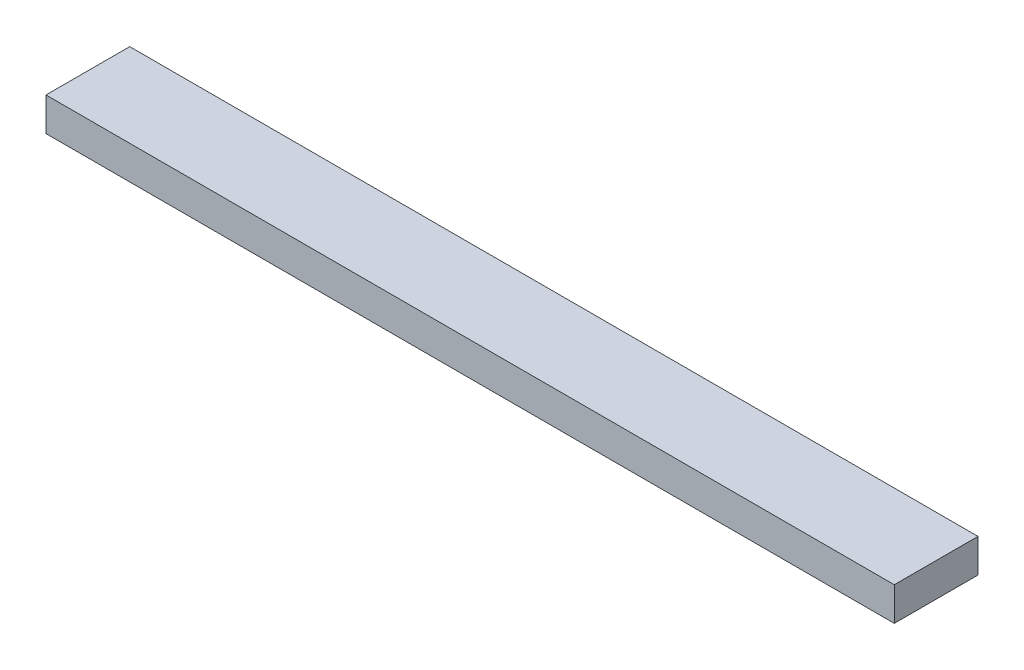
from build123d import *

# Parameters (mm, degrees)
SKETCH_1_W      = 304
SKETCH_1_H      = 12
EXTRUDE_1_DEPTH = 30


with BuildPart() as part:
    # 草图1 → 凸台-拉伸1 (new body)
    with BuildSketch(Plane.XY):
        with Locations((0, 20.057142857)):
            Rectangle(SKETCH_1_W, SKETCH_1_H)
    extrude(amount=EXTRUDE_1_DEPTH)


solid = part.part
